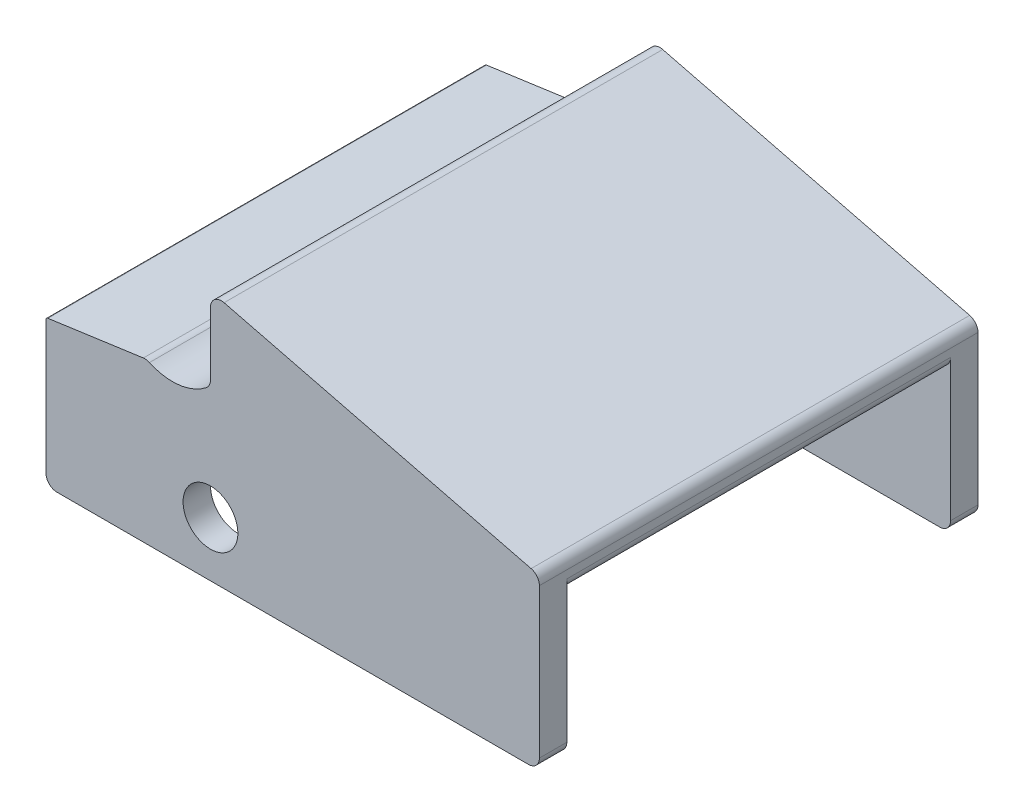
from build123d import *

# Parameters (mm, degrees)
SKETCH1_R           = 3.175
BOSS_EXTRUDE1_DEPTH = 25.4
SKETCH1_4_W         = 57.15
SKETCH1_4_H         = 16.383
SKETCH1_4_R         = 3.175
CUT_EXTRUDE1_DEPTH  = 22.225
FILLET2_R           = 1.27
FILLET3_R           = 0.254


with BuildPart() as part:
    # Sketch1 → Boss-Extrude1 (new, symmetric)
    with BuildSketch(Plane.XY):
        with BuildLine():
            Line((-9.525, 20.8915), (-9.525, 11.3665))
            ThreePointArc((-9.525, 11.3665), (-13.050132349, 9.650975764), (-16.910848847, 10.332481161))
            Line((-16.910848847, 10.332481161), (-28.575, 8.6995))
            Line((-28.575, 8.6995), (-28.575, -8.1915))
            Line((-28.575, -8.1915), (28.575, -8.1915))
            Line((28.575, -8.1915), (28.575, 11.3665))
            Line((28.575, 11.3665), (-9.525, 20.8915))
        make_face()
        with Locations((-9.525, -1.8415)):
            Circle(SKETCH1_R, mode=Mode.SUBTRACT)
    extrude(amount=BOSS_EXTRUDE1_DEPTH, both=True)

    # Sketch1_4 → Cut-Extrude1 (cut, symmetric)
    with BuildSketch(Plane.XY):
        Rectangle(SKETCH1_4_W, SKETCH1_4_H)
        with Locations((-9.525, -1.8415)):
            Circle(SKETCH1_4_R, mode=Mode.SUBTRACT)
    extrude(amount=CUT_EXTRUDE1_DEPTH, both=True, mode=Mode.SUBTRACT)

    # Fillet2
    fillet2_edges = [part.edges().sort_by_distance(p)[0] for p in [
        (28.575, 8.1915, 0),
        (28.575, 11.3665, 0),
        (-9.525, 20.8915, 0),
        (-28.575, -8.1915, 23.8125),
        (-28.575, -8.1915, -23.8125),
        (28.575, -8.1915, -23.8125),
        (28.575, -8.1915, 23.8125),
        (-16.910848847, 10.332481161, 0),
        (-9.525, 11.3665, 0),
    ]]
    fillet(fillet2_edges, radius=FILLET2_R)

    # Fillet3
    fillet3_edges = [part.edges().sort_by_distance(p)[0] for p in [
        (-28.575, 8.1915, 0),
        (-28.575, 8.6995, 0),
    ]]
    fillet(fillet3_edges, radius=FILLET3_R)


solid = part.part
